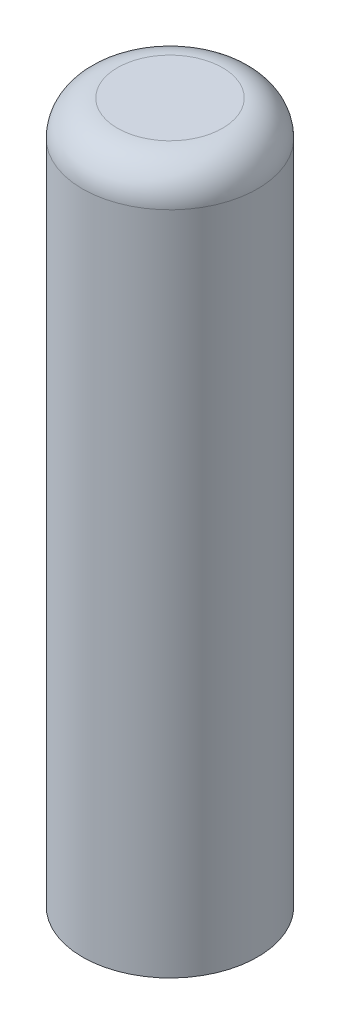
from build123d import *

# Parameters (mm, degrees)
SKETCH2_R           = 2.5
SKETCH2_W           = 1.95
SKETCH2_H           = 1.2
BOSS_EXTRUDE1_DEPTH = 10
FILLET1_R           = 1
SKETCH3_W           = 1.95
SKETCH3_H           = 1.2
BOSS_EXTRUDE5_DEPTH = 16


with BuildPart() as part:
    # Sketch2 → Boss-Extrude1 (new body, symmetric)
    with BuildSketch(Plane(origin=(0, 0, 0), x_dir=(1, 0, 0), z_dir=(0, 1, 0))):
        Circle(SKETCH2_R)
        Rectangle(SKETCH2_W, SKETCH2_H, mode=Mode.SUBTRACT)
    extrude(amount=BOSS_EXTRUDE1_DEPTH, both=True)

    # Fillet1
    fillet1_edges = [part.edges().sort_by_distance(p)[0] for p in [
        (-2.5, 10, 0),
    ]]
    fillet(fillet1_edges, radius=FILLET1_R)

    # Sketch3 → Boss-Extrude5 (add)
    with BuildSketch(Plane(origin=(0, 10, 0), x_dir=(1, 0, 0), z_dir=(0, 1, 0))):
        Rectangle(SKETCH3_W, SKETCH3_H)
    extrude(amount=-BOSS_EXTRUDE5_DEPTH)


solid = part.part
